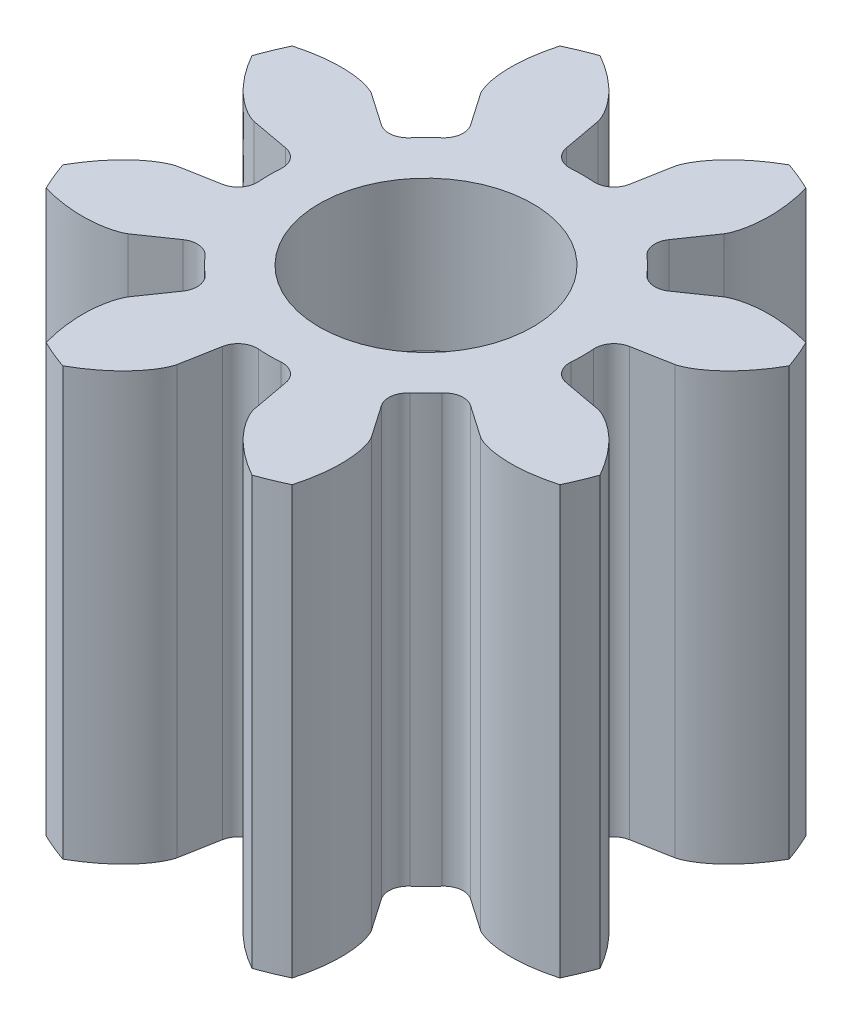
from build123d import *

# Parameters (mm, degrees)
SKETCH1_R                = 6.666666667
BOSS_EXTRUDE1_DEPTH      = 10
CUT_EXTRUDE1_DEPTH       = 11
FILLET1_R                = 0.447340048
CIRPATTERN1_COUNT        = 8
FILLET1_OF_CIRPATTERN1_R = 0.447340048
SKETCH3_R                = 2.5
CUT_EXTRUDE2_DEPTH       = 3.5
SKETCH4_R                = 2.5
CUT_EXTRUDE3_DEPTH       = 3.5
SKETCH5_R                = 1.1
CUT_EXTRUDE4_DEPTH       = 7.5000001
BOSS_EXTRUDE2_DEPTH      = 3.5
CIRPATTERN2_COUNT        = 36


with BuildPart() as part:
    # Sketch1 → Boss-Extrude1 (new body)
    with BuildSketch(Plane(origin=(0, 0, 0), x_dir=(1, 0, 0), z_dir=(0, 1, 0))):
        Circle(SKETCH1_R)
    extrude(amount=BOSS_EXTRUDE1_DEPTH)

    # Sketch2 → Cut-Extrude1 (cut, through all)
    with BuildSketch(Plane.XZ):
        with BuildLine():
            Line((4.929421707, 0.904366165), (3.606474445, 0.66165438))
            ThreePointArc((3.606474445, 0.66165438), (3.666666667, 0), (3.606474445, -0.66165438))
            Line((3.606474445, -0.66165438), (4.929421707, -0.904366165))
            add(Edge.make_bspline(
                [(4.929421707, -0.904366165), (4.932216443, -0.904932699), (4.940021079, -0.906682019), (4.954636137, -0.910621012), (4.978248082, -0.917936768), (5.021573733, -0.933420914), (5.072553137, -0.955093632), (5.12898261, -0.98256319), (5.188373498, -1.015028138), (5.238324964, -1.044589241), (5.28734072, -1.075732516), (5.335406683, -1.108233998), (5.392685609, -1.149321159), (5.460026171, -1.200960377), (5.536666087, -1.264690901), (5.621054116, -1.340890756), (5.7041962, -1.422610343), (5.783603323, -1.506319168), (5.860927849, -1.594545992), (5.933672193, -1.682490029), (6.006088206, -1.777397369), (6.071343567, -1.866830123), (6.140827646, -1.970789706), (6.195854846, -2.055802261), (6.249581947, -2.146633122), (6.275267105, -2.191279194), (6.288196615, -2.214278161)],
                knots=[0, 0, 0, 0, 0, 0.005376748, 0.015083688, 0.02853182, 0.046610139, 0.092110525, 0.119476175, 0.146842495, 0.174208854, 0.201574955, 0.228941013, 0.256307345, 0.307035032, 0.361767351, 0.41649966, 0.471231936, 0.525964282, 0.580696615, 0.635428982, 0.690161387, 0.744893688, 0.799626083, 0.854358408, 0.909090915, 0.909090915, 0.909090915, 0.909090915, 0.909090915], degree=4))
            ThreePointArc((6.288196615, -2.214278161), (6.571368016, -1.123194924), (6.666666667, 0))
            ThreePointArc((6.666666667, 0), (6.571368016, 1.123194924), (6.288196615, 2.214278161))
            add(Edge.make_bspline(
                [(4.929421707, 0.904366165), (4.932216443, 0.904932699), (4.940021079, 0.906682019), (4.954636137, 0.910621012), (4.978248082, 0.917936768), (5.021573733, 0.933420914), (5.072553137, 0.955093632), (5.12898261, 0.98256319), (5.188373498, 1.015028138), (5.238324964, 1.044589241), (5.28734072, 1.075732516), (5.335406683, 1.108233998), (5.392685609, 1.149321159), (5.460026171, 1.200960377), (5.536666087, 1.264690901), (5.621054116, 1.340890756), (5.7041962, 1.422610343), (5.783603323, 1.506319168), (5.860927849, 1.594545992), (5.933672193, 1.682490029), (6.006088206, 1.777397369), (6.071343567, 1.866830123), (6.140827646, 1.970789706), (6.195854846, 2.055802261), (6.249581947, 2.146633122), (6.275267105, 2.191279194), (6.288196615, 2.214278161)],
                knots=[0, 0, 0, 0, 0, 0.005376748, 0.015083688, 0.02853182, 0.046610139, 0.092110525, 0.119476175, 0.146842495, 0.174208854, 0.201574955, 0.228941013, 0.256307345, 0.307035032, 0.361767351, 0.41649966, 0.471231936, 0.525964282, 0.580696615, 0.635428982, 0.690161387, 0.744893688, 0.799626083, 0.854358408, 0.909090915, 0.909090915, 0.909090915, 0.909090915, 0.909090915], degree=4))
        make_face()
    cut_extrude1 = extrude(amount=-CUT_EXTRUDE1_DEPTH, mode=Mode.SUBTRACT)

    # Fillet1
    fillet1_edges = [part.edges().sort_by_distance(p)[0] for p in [
        (3.606474445, 5, -0.66165438),
        (3.606474445, 5, 0.66165438),
    ]]
    fillet(fillet1_edges, radius=FILLET1_R)

    # CirPattern1: Cut-Extrude1 ×8 about axis
    cirpattern1_axis = Axis((0, 10, 0), (0, -1, 0))
    for i in range(1, CIRPATTERN1_COUNT):
        add(cut_extrude1.rotate(cirpattern1_axis, i * 360 / CIRPATTERN1_COUNT), mode=Mode.SUBTRACT)

    # Fillet1 of CirPattern1
    fillet1_of_cirpattern1_edges = [part.edges().sort_by_distance(p)[0] for p in [
        (3.018022836, 5, 2.082302238),
        (2.082302238, 5, 3.018022836),
        (0.66165438, 5, 3.606474445),
        (-0.66165438, 5, 3.606474445),
        (-2.082302238, 5, 3.018022836),
        (-3.018022836, 5, 2.082302238),
        (-3.606474445, 5, 0.66165438),
        (-3.606474445, 5, -0.66165438),
        (-3.018022836, 5, -2.082302238),
        (-2.082302238, 5, -3.018022836),
        (-0.66165438, 5, -3.606474445),
        (0.66165438, 5, -3.606474445),
        (2.082302238, 5, -3.018022836),
        (3.018022836, 5, -2.082302238),
    ]]
    fillet(fillet1_of_cirpattern1_edges, radius=FILLET1_OF_CIRPATTERN1_R)

    # Sketch3 → Cut-Extrude2 (cut)
    with BuildSketch(Plane.XZ):
        Circle(SKETCH3_R)
    extrude(amount=-CUT_EXTRUDE2_DEPTH, mode=Mode.SUBTRACT)

    # Sketch4 → Cut-Extrude3 (cut)
    with BuildSketch(Plane(origin=(0, 10, 0), x_dir=(1, 0, 0), z_dir=(0, 1, 0))):
        Circle(SKETCH4_R)
    extrude(amount=-CUT_EXTRUDE3_DEPTH, mode=Mode.SUBTRACT)

    # Sketch5 → Cut-Extrude4 (cut, through all)
    with BuildSketch(Plane(origin=(0, 6.5, 0), x_dir=(1, 0, 0), z_dir=(0, 1, 0))):
        Circle(SKETCH5_R)
    extrude(amount=-CUT_EXTRUDE4_DEPTH, mode=Mode.SUBTRACT)

    # Sketch6 → Boss-Extrude2 (add)
    with BuildSketch(Plane.XZ):
        with BuildLine():
            ThreePointArc((-0.2, 2.491987159), (0, 2.5), (0.2, 2.491987159))
            Line((0.2, 2.491987159), (0, 2.4))
            Line((0, 2.4), (-0.2, 2.491987159))
        make_face()
    boss_extrude2 = extrude(amount=-BOSS_EXTRUDE2_DEPTH)

    # CirPattern2: Boss-Extrude2 ×36 about axis
    cirpattern2_axis = Axis((0, 0, 0), (0, 1, 0))
    for i in range(1, CIRPATTERN2_COUNT):
        add(boss_extrude2.rotate(cirpattern2_axis, i * 360 / CIRPATTERN2_COUNT))


solid = part.part
